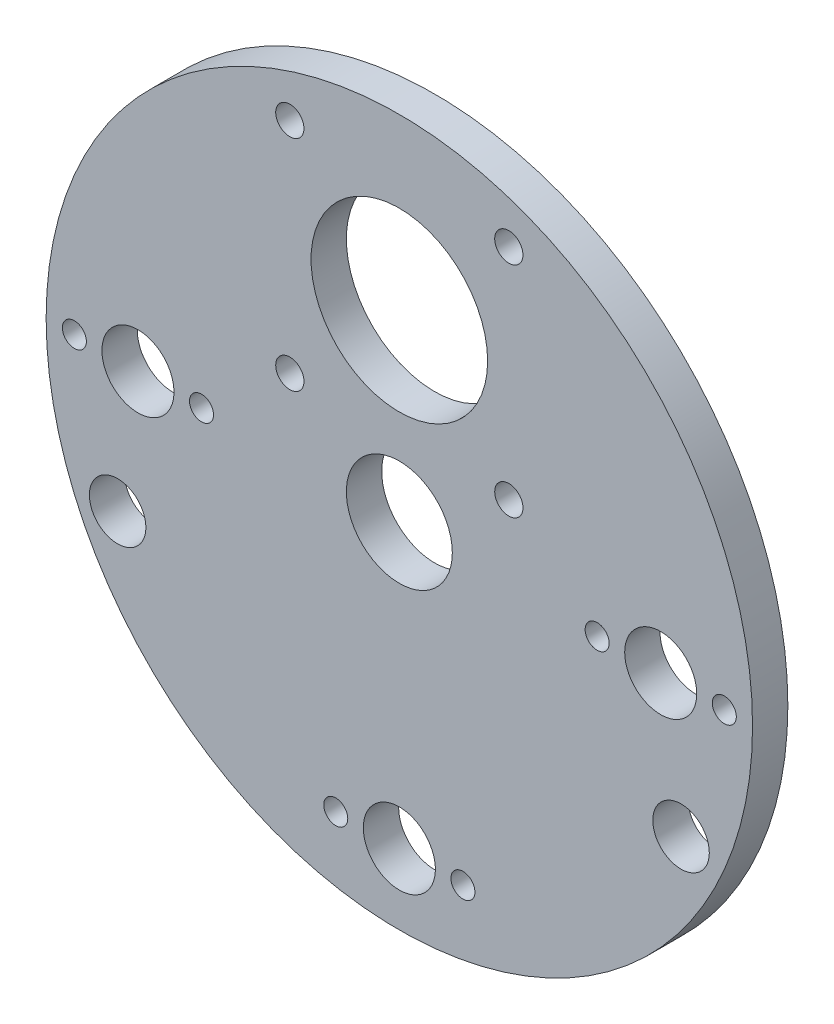
from build123d import *

# Parameters (mm, degrees)
SKETCH1_R                    = 50
BOSS_EXTRUDE1_DEPTH          = 5
F_10_2_10_2_DIAMETER_HOLE1_D = 10.2
M3_CLEARANCE_HOLE1_D         = 3.4
SKETCH12_R                   = 12.5
CUT_EXTRUDE2_DEPTH           = 10
SKETCH13_R                   = 2
CUT_EXTRUDE3_DEPTH           = 10
CIRPATTERN1_COUNT            = 4
SKETCH14_R                   = 4
CUT_EXTRUDE4_DEPTH           = 10
SKETCH15_R                   = 7.5
CUT_EXTRUDE5_DEPTH           = 10


with BuildPart() as part:
    # Sketch1 → Boss-Extrude1 (new body)
    with BuildSketch(Plane.XY):
        Circle(SKETCH1_R)
    extrude(amount=BOSS_EXTRUDE1_DEPTH)

    # Ø10.2 (10.2) Diameter Hole1 (through all)
    with Locations(Plane(origin=(0, 0, 0), x_dir=(-1, 0, 0), z_dir=(0, 0, -1))):
        with Locations((37, 0), (-37, 0), (0, -40)):
            Hole(F_10_2_10_2_DIAMETER_HOLE1_D / 2)

    # M3 Clearance Hole1 (through all)
    with Locations(Plane.XY.offset(5)):
        with Locations((46, 0), (28, 0), (9, -40), (-9, -40), (-46, 0), (-28, 0)):
            Hole(M3_CLEARANCE_HOLE1_D / 2)

    # Sketch12 → Cut-Extrude2 (cut)
    with BuildSketch(Plane.XY.offset(5)):
        with Locations((0, 26)):
            Circle(SKETCH12_R)
    extrude(amount=-CUT_EXTRUDE2_DEPTH, mode=Mode.SUBTRACT)

    # Sketch13 → Cut-Extrude3 (cut)
    with BuildSketch(Plane.XY.offset(5)):
        with Locations((-15.5, 41.5)):
            Circle(SKETCH13_R)
    cut_extrude3 = extrude(amount=-CUT_EXTRUDE3_DEPTH, mode=Mode.SUBTRACT)

    # CirPattern1: Cut-Extrude3 ×4 about axis
    cirpattern1_axis = Axis((0, 26, 0), (0, 0, 1))
    for i in range(1, CIRPATTERN1_COUNT):
        add(cut_extrude3.rotate(cirpattern1_axis, i * 360 / CIRPATTERN1_COUNT), mode=Mode.SUBTRACT)

    # Sketch14 → Cut-Extrude4 (cut)
    with BuildSketch(Plane.XY.offset(5)):
        with Locations((-39.87754263, -18.595203517)):
            Circle(SKETCH14_R)
        with Locations((39.87754263, -18.595203517)):
            Circle(SKETCH14_R)
    extrude(amount=-CUT_EXTRUDE4_DEPTH, mode=Mode.SUBTRACT)

    # Sketch15 → Cut-Extrude5 (cut)
    with BuildSketch(Plane.XY.offset(5)):
        Circle(SKETCH15_R)
    extrude(amount=-CUT_EXTRUDE5_DEPTH, mode=Mode.SUBTRACT)


solid = part.part
